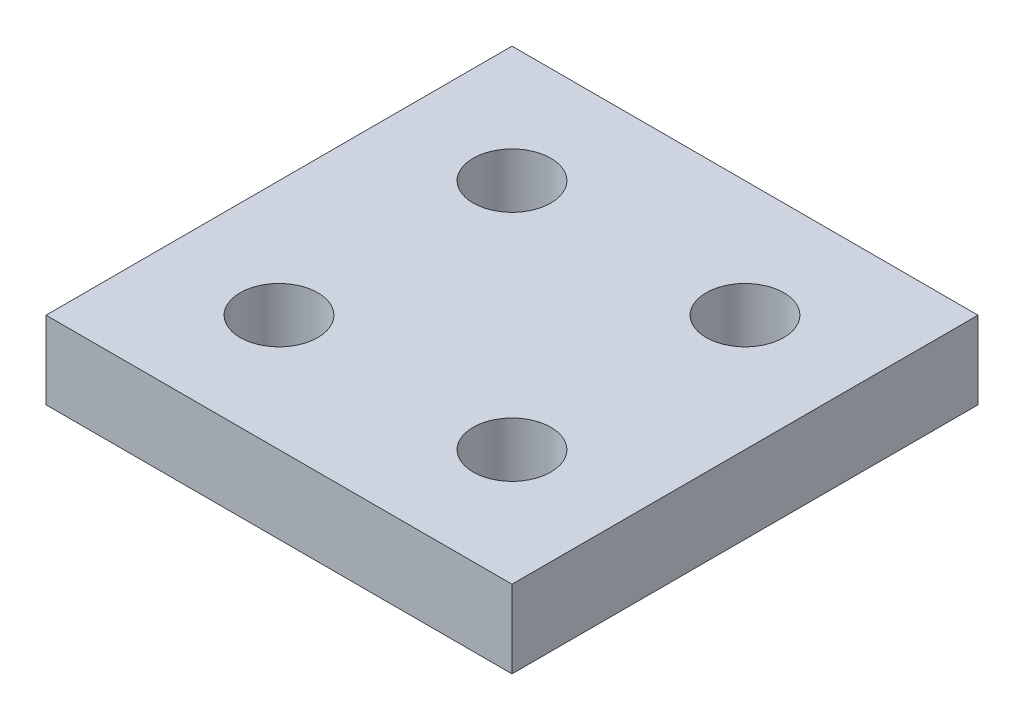
from build123d import *

# Parameters (mm, degrees)
SKETCH1_W           = 60
SKETCH1_H           = 60
SKETCH1_R           = 5
BOSS_EXTRUDE1_DEPTH = 10


with BuildPart() as part:
    # Sketch1 → Boss-Extrude1 (new body)
    with BuildSketch(Plane(origin=(0, 0, 0), x_dir=(1, 0, 0), z_dir=(0, 1, 0))):
        with Locations((30, 30)):
            Rectangle(SKETCH1_W, SKETCH1_H)
        with Locations((15, 45)):
            Circle(SKETCH1_R, mode=Mode.SUBTRACT)
        with Locations((45, 45)):
            Circle(SKETCH1_R, mode=Mode.SUBTRACT)
        with Locations((45, 15)):
            Circle(SKETCH1_R, mode=Mode.SUBTRACT)
        with Locations((15, 15)):
            Circle(SKETCH1_R, mode=Mode.SUBTRACT)
    extrude(amount=BOSS_EXTRUDE1_DEPTH)


solid = part.part
